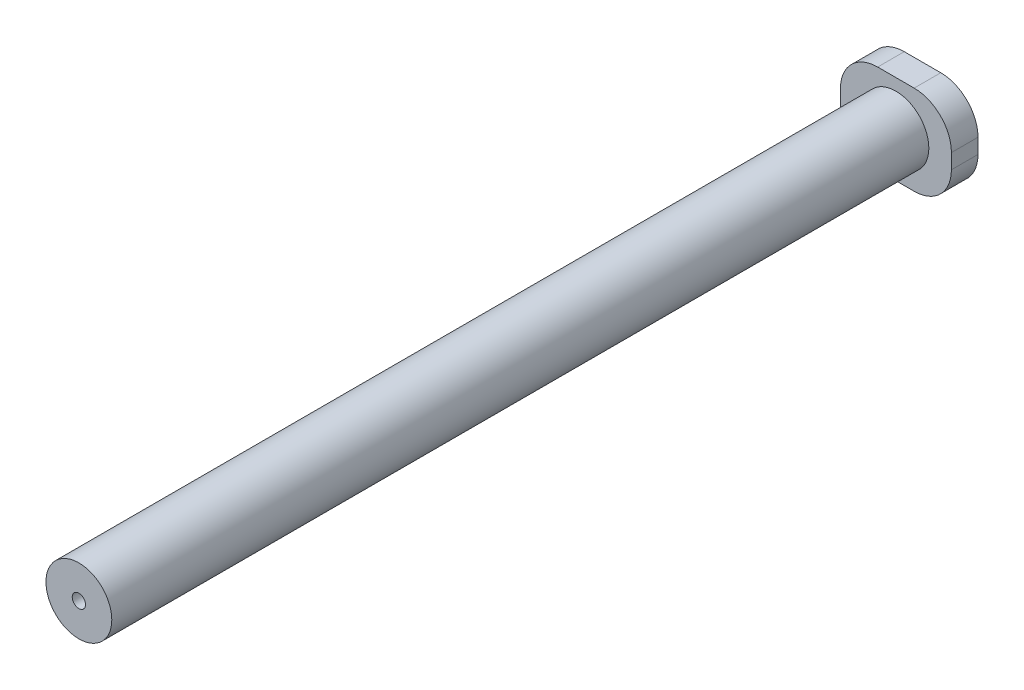
from build123d import *

# Parameters (mm, degrees)
SKETCH1_W           = 13.2461
SKETCH1_H           = 10.668
SKETCH1_R           = 3.93065
BOSS_EXTRUDE1_DEPTH = 3.175
SKETCH1_2_R         = 3.93065
SKETCH1_2_R_2       = 0.79375
BOSS_EXTRUDE2_DEPTH = 100.711
FILLET1_R           = 4.445


with BuildPart() as part:
    # Sketch1 → Boss-Extrude1 (new body)
    with BuildSketch(Plane.XY):
        with Locations((6.62305, 5.334)):
            Rectangle(SKETCH1_W, SKETCH1_H)
        with Locations((6.62305, 5.334)):
            Circle(SKETCH1_R, mode=Mode.SUBTRACT)
    extrude(amount=BOSS_EXTRUDE1_DEPTH)

    # Sketch1_2 → Boss-Extrude2 (add)
    with BuildSketch(Plane.XY):
        with Locations((6.62305, 5.334)):
            Circle(SKETCH1_2_R)
        with Locations((6.62305, 5.334)):
            Circle(SKETCH1_2_R_2, mode=Mode.SUBTRACT)
    extrude(amount=BOSS_EXTRUDE2_DEPTH)

    # Fillet1
    fillet1_edges = [part.edges().sort_by_distance(p)[0] for p in [
        (0, 0, 1.5875),
        (13.2461, 0, 1.5875),
        (13.2461, 10.668, 1.5875),
        (0, 10.668, 1.5875),
    ]]
    fillet(fillet1_edges, radius=FILLET1_R)


solid = part.part
